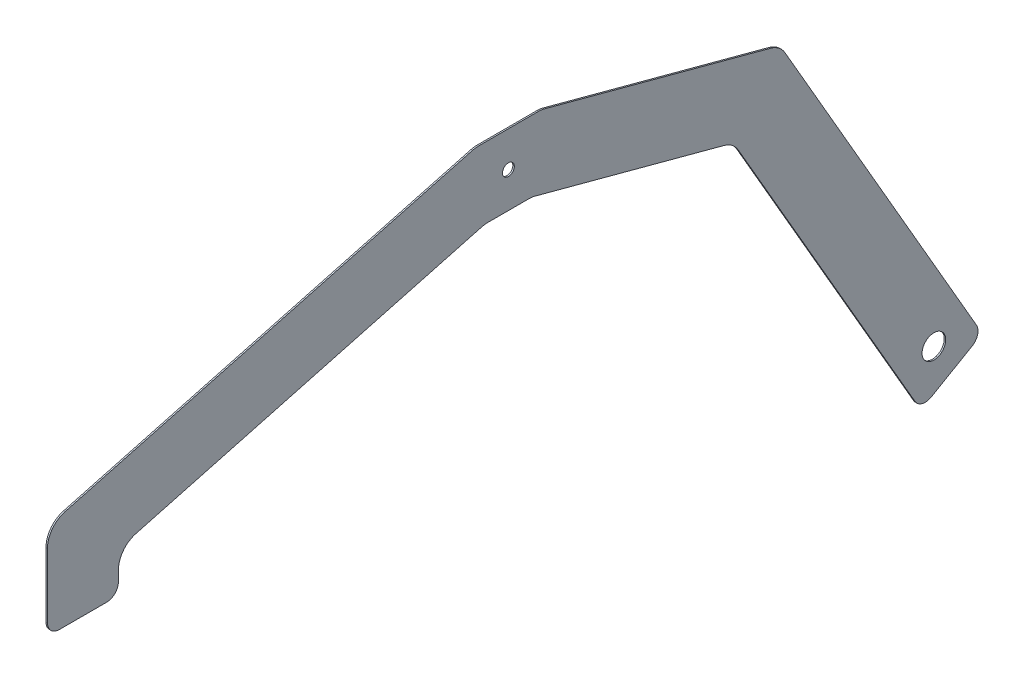
from build123d import *

# Parameters (mm, degrees)
SKETCH1_R           = 6.35
SKETCH1_R_2         = 12.7
BOSS_EXTRUDE1_DEPTH = 1.5875
FILLET1_R           = 25.4
FILLET2_R           = 25.4
FILLET3_R           = 25.4
FILLET4_R           = 25.4
FILLET5_R           = 12.7


with BuildPart() as part:
    # Sketch1 → Boss-Extrude1 (new body)
    with BuildSketch(Plane(origin=(0, 0, 0), x_dir=(0, 0, -1), z_dir=(1, 0, 0))):
        Polygon((-35.431920316, 38.1), (35.431920316, 38.1), (291.921947077, -30.626295537), (509.245567884, -407.04184846), (443.254432116, -445.14184846), (241.712348035, -96.060718969), (25.4, -38.1), (-25.4, -38.1), (-419.1, -143.59159706), (-419.1, -186.721280576), (-495.3, -186.721280576), (-495.3, -85.121280576), align=None)
        Circle(SKETCH1_R, mode=Mode.SUBTRACT)
        with Locations((457.2, -393.096280576)):
            Circle(SKETCH1_R_2, mode=Mode.SUBTRACT)
    extrude(amount=BOSS_EXTRUDE1_DEPTH)

    # Fillet1
    fillet1_edges = [part.edges().sort_by_distance(p)[0] for p in [
        (0.79375, -85.121280576, 495.3),
    ]]
    fillet(fillet1_edges, radius=FILLET1_R)

    # Fillet2
    fillet2_edges = [part.edges().sort_by_distance(p)[0] for p in [
        (0.79375, -143.59159706, 419.1),
    ]]
    fillet(fillet2_edges, radius=FILLET2_R)

    # Fillet3
    fillet3_edges = [part.edges().sort_by_distance(p)[0] for p in [
        (0.79375, -96.060718969, -241.712348035),
        (0.79375, -38.1, -25.4),
        (0.79375, -38.1, 25.4),
    ]]
    fillet(fillet3_edges, radius=FILLET3_R)

    # Fillet4
    fillet4_edges = [part.edges().sort_by_distance(p)[0] for p in [
        (0.79375, 38.1, 35.431920316),
        (0.79375, 38.1, -35.431920316),
        (0.79375, -30.626295537, -291.921947077),
    ]]
    fillet(fillet4_edges, radius=FILLET4_R)

    # Fillet5
    fillet5_edges = [part.edges().sort_by_distance(p)[0] for p in [
        (0.79375, -186.721280576, 419.1),
        (0.79375, -186.721280576, 495.3),
        (0.79375, -407.04184846, -509.245567884),
        (0.79375, -445.14184846, -443.254432116),
    ]]
    fillet(fillet5_edges, radius=FILLET5_R)


solid = part.part
